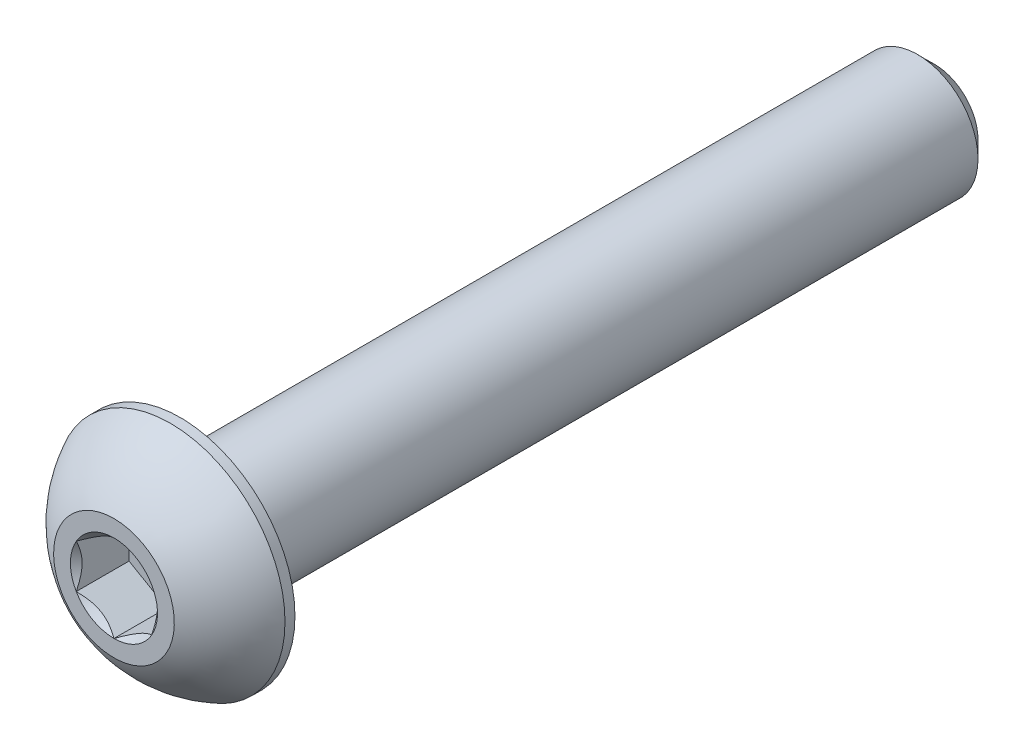
from build123d import *

# Parameters (mm, degrees)
CUT_EXTRUDE1_DEPTH = 1.75


with BuildPart() as part:
    # Sketch2 → Revolve1 (revolve)
    with BuildSketch(Plane(origin=(0, 0, 0), x_dir=(0, 0, -1), z_dir=(1, 0, 0)), mode=Mode.PRIVATE) as revolve1_sk:
        with BuildLine():
            Line((-13.6, 0), (13.6, 0))
            Line((13.6, 0), (13.6, 1.44))
            Line((13.6, 1.44), (13.04, 2))
            Line((13.04, 2), (-11.4, 2))
            Line((-11.4, 2), (-11.4, 3.8))
            Line((-11.4, 3.8), (-11.73, 3.8))
            ThreePointArc((-11.73, 3.8), (-12.806499853, 3.047002626), (-13.6, 2))
            Line((-13.6, 2), (-13.6, 0))
        make_face()
    revolve(revolve1_sk.sketch.rotate(Axis((0, 0, 13.6), (0, 0, -1)), 90), axis=Axis((0, 0, 13.6), (0, 0, -1)))

    # Sketch3 → Cut-Extrude1 (cut)
    with BuildSketch(Plane.XY.offset(13.6)):
        Polygon((0, 1.443375673), (-1.25, 0.721687836), (-1.25, -0.721687836), (0, -1.443375673), (1.25, -0.721687836), (1.25, 0.721687836), align=None)
    extrude(amount=-CUT_EXTRUDE1_DEPTH, mode=Mode.SUBTRACT)

    # Cut-Extrude2 cone 1 section (through the dimple's axis) → Cut-Extrude2 (revolve, cut)
    with BuildSketch(Plane(origin=(0, 0, 13.6), x_dir=(0, -1, 0), z_dir=(1, 0, 0))):
        Polygon((0, 0), (1.443375673, 0), (0, 1.443375673), align=None)
    revolve(axis=Axis((0, 0, 13.6), (0, 0, -1)), mode=Mode.SUBTRACT)


solid = part.part
